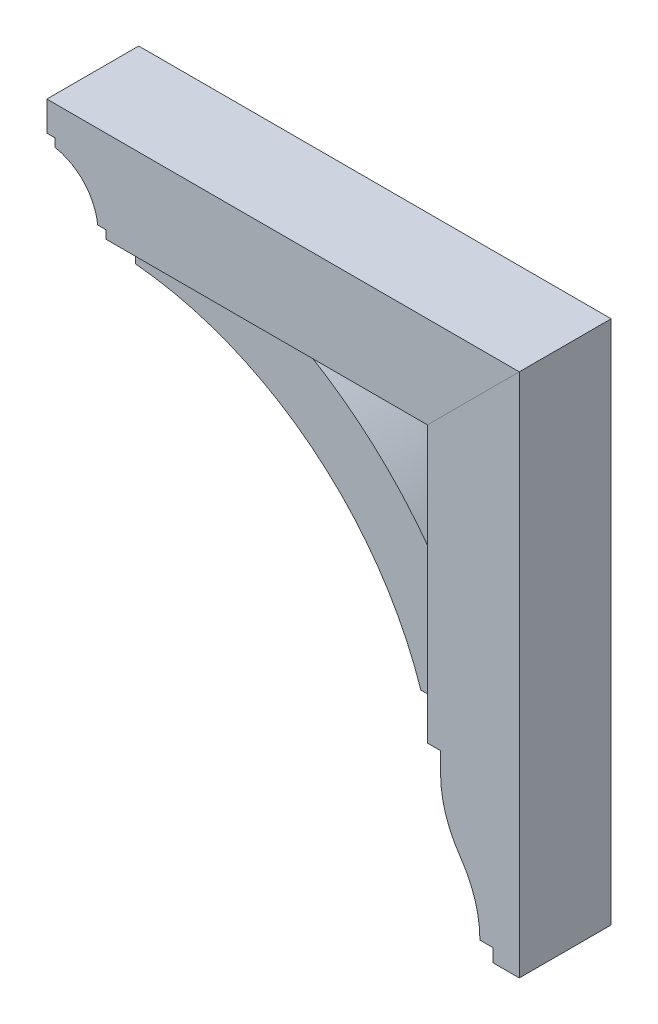
from build123d import *

# Parameters (mm, degrees)
BOSS_EXTRUDE1_DEPTH = 44.45
BOSS_EXTRUDE2_DEPTH = 31.75
BOSS_EXTRUDE3_DEPTH = 44.45


with BuildPart() as part:
    # Sketch1 → Boss-Extrude1 (new body, symmetric)
    with BuildSketch(Plane.XY):
        with BuildLine():
            Line((-126.181276984, 135.5725), (-126.181276984, 143.51))
            Line((-126.181276984, 143.51), (-134.118776984, 143.51))
            Line((-134.118776984, 143.51), (-134.118776984, 172.085))
            Line((-134.118776984, 172.085), (323.081223016, 172.085))
            Line((323.081223016, 172.085), (234.181223016, 83.185))
            Line((234.181223016, 83.185), (-76.968776984, 83.185))
            Line((-76.968776984, 83.185), (-76.968776984, 91.1225))
            Line((-76.968776984, 91.1225), (-84.906276984, 91.1225))
            ThreePointArc((-84.906276984, 91.1225), (-98.169132336, 120.195384316), (-126.181276984, 135.5725))
        make_face()
    extrude(amount=BOSS_EXTRUDE1_DEPTH, both=True)


with BuildPart() as body_2:
    # Sketch1_3 → Boss-Extrude2 (new body, symmetric)
    with BuildSketch(Plane.XY):
        with BuildLine():
            ThreePointArc((234.181223016, -48.5775), (169.73213851, 26.809584042), (88.131223016, 83.185))
            Line((88.131223016, 83.185), (-61.093776984, 83.185))
            Line((-61.093776984, 83.185), (-61.093776984, 64.135))
            ThreePointArc((-61.093776984, 64.135), (109.632978176, -4.280178276), (215.131223016, -154.94))
            Line((215.131223016, -154.94), (234.181223016, -154.94))
            Line((234.181223016, -154.94), (234.181223016, -48.5775))
        make_face()
    extrude(amount=BOSS_EXTRUDE2_DEPTH, both=True)


with BuildPart() as body_3:
    # Sketch1_4 → Boss-Extrude3 (new body, symmetric)
    with BuildSketch(Plane.XY):
        with BuildLine():
            Line((323.081223016, -335.915), (323.081223016, 172.085))
            Line((323.081223016, 172.085), (234.181223016, 83.185))
            Line((234.181223016, 83.185), (234.181223016, -183.515))
            Line((234.181223016, -183.515), (246.881223016, -183.515))
            Line((246.881223016, -183.515), (246.881223016, -202.565))
            ThreePointArc((246.881223016, -202.565), (251.744599276, -234.116039076), (265.883238129, -262.738047859))
            ThreePointArc((265.883238129, -262.738047859), (280.093284249, -291.504612242), (284.981223016, -323.215))
            Line((284.981223016, -323.215), (297.681223016, -323.215))
            Line((297.681223016, -323.215), (297.681223016, -335.915))
            Line((297.681223016, -335.915), (323.081223016, -335.915))
        make_face()
    extrude(amount=BOSS_EXTRUDE3_DEPTH, both=True)


solid = Compound([part.part, body_2.part, body_3.part])
